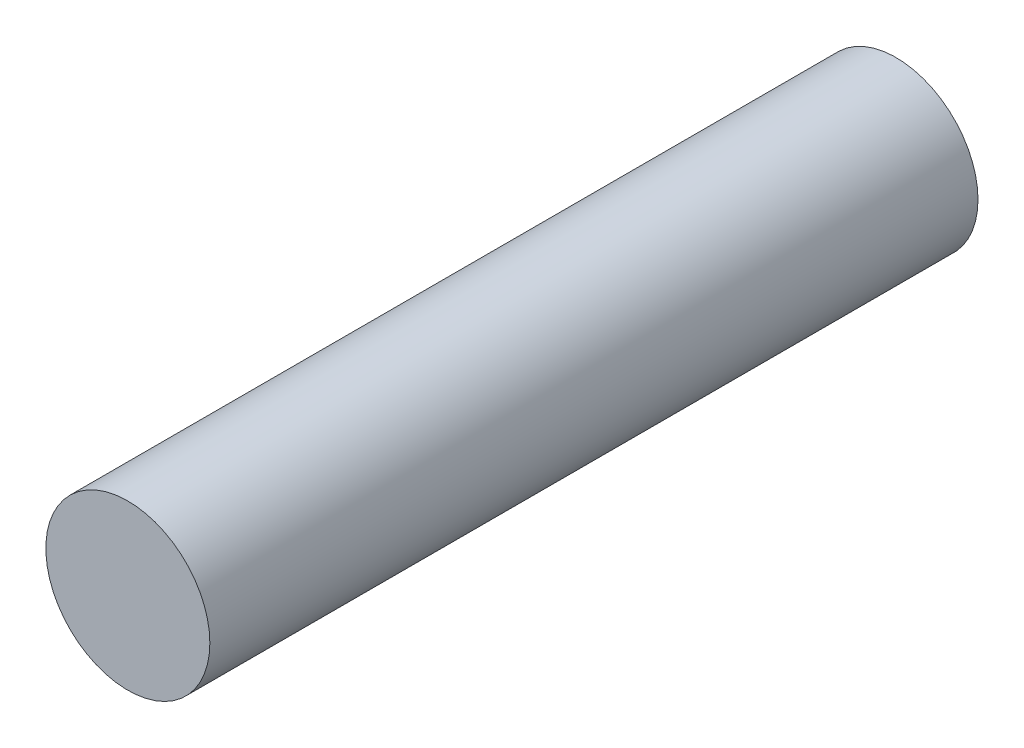
from build123d import *

# Parameters (mm, degrees)
SKETCH1_R           = 1.5
BOSS_EXTRUDE1_DEPTH = 14.05


with BuildPart() as part:
    # Sketch1 → Boss-Extrude1 (new body)
    with BuildSketch(Plane.XY):
        Circle(SKETCH1_R)
    extrude(amount=BOSS_EXTRUDE1_DEPTH)


solid = part.part
